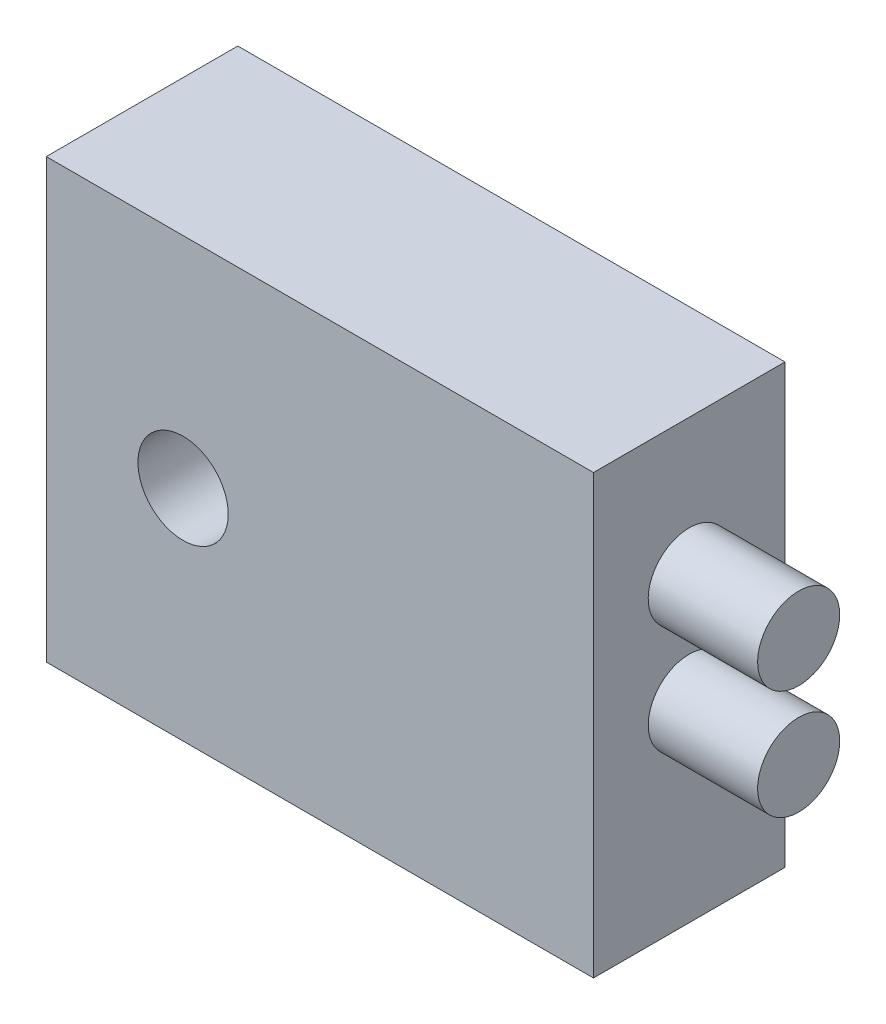
from build123d import *

# Parameters (mm, degrees)
SKETCH1_W           = 20
SKETCH1_H           = 16
SKETCH1_R           = 1.65
BOSS_EXTRUDE1_DEPTH = 7
SKETCH2_R           = 1.5
BOSS_EXTRUDE2_DEPTH = 4


with BuildPart() as part:
    # Sketch1 → Boss-Extrude1 (new body)
    with BuildSketch(Plane.XY):
        with Locations((10, 8)):
            Rectangle(SKETCH1_W, SKETCH1_H)
        with Locations((5, 8)):
            Circle(SKETCH1_R, mode=Mode.SUBTRACT)
    extrude(amount=BOSS_EXTRUDE1_DEPTH)

    # Sketch2 → Boss-Extrude2 (add)
    with BuildSketch(Plane(origin=(20, 0, 0), x_dir=(0, 0, -1), z_dir=(1, 0, 0))):
        with Locations((-3.5, 7)):
            Circle(SKETCH2_R)
        with Locations((-3.5, 11)):
            Circle(SKETCH2_R)
    extrude(amount=BOSS_EXTRUDE2_DEPTH)


solid = part.part
